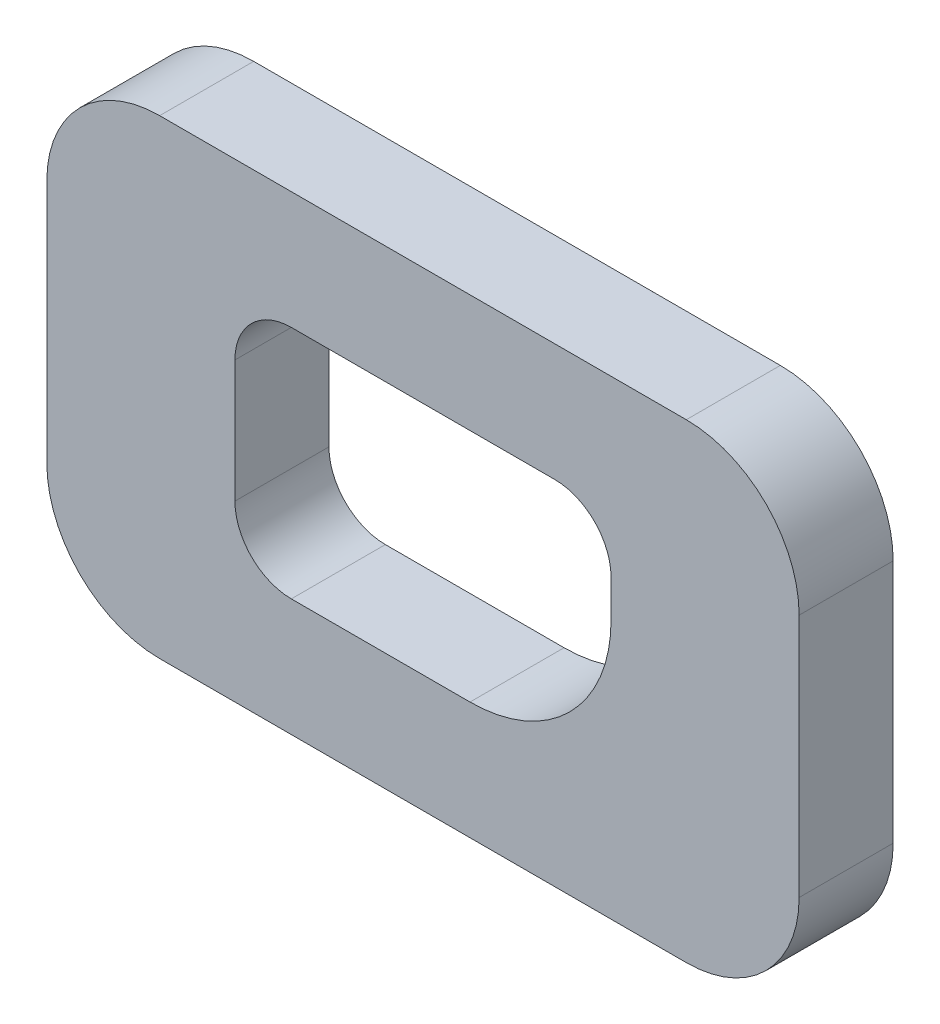
from build123d import *

# Parameters (mm, degrees)
BOSS_EXTRU_5_DEPTH = 10


with BuildPart() as part:
    # Esquisse4 → Boss.-Extru.5 (new body)
    with BuildSketch(Plane.XY):
        with BuildLine():
            Line((-28, -25), (28, -25))
            ThreePointArc((28, -25), (36.485281374, -21.485281374), (40, -13))
            Line((40, -13), (40, 13))
            ThreePointArc((40, 13), (36.485281374, 21.485281374), (28, 25))
            Line((28, 25), (-28, 25))
            ThreePointArc((-28, 25), (-36.485281374, 21.485281374), (-40, 13))
            Line((-40, 13), (-40, -13))
            ThreePointArc((-40, -13), (-36.485281374, -21.485281374), (-28, -25))
        make_face()
        with BuildLine():
            Line((-14, -12.5), (5, -12.5))
            ThreePointArc((5, -12.5), (15.606601718, -8.106601718), (20, 2.5))
            Line((20, 2.5), (20, 6.5))
            ThreePointArc((20, 6.5), (18.242640687, 10.742640687), (14, 12.5))
            Line((14, 12.5), (-14, 12.5))
            ThreePointArc((-14, 12.5), (-18.242640687, 10.742640687), (-20, 6.5))
            Line((-20, 6.5), (-20, -6.5))
            ThreePointArc((-20, -6.5), (-18.242640687, -10.742640687), (-14, -12.5))
        make_face(mode=Mode.SUBTRACT)
    extrude(amount=BOSS_EXTRU_5_DEPTH)


solid = part.part
